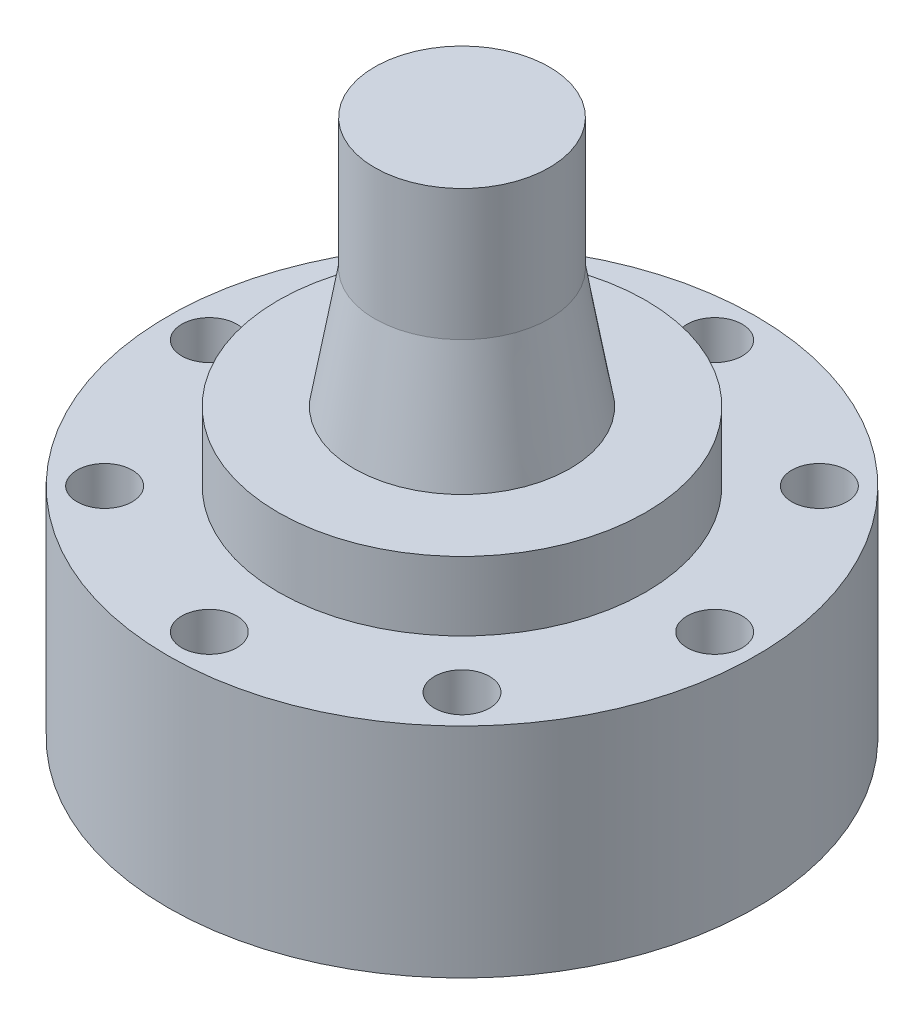
from build123d import *

# Parameters (mm, degrees)
SKETCH_1_R           = 12.8
EXTRUDE_1_DEPTH      = 9.5
EXTRUDE_1_DEPTH_BACK = 3
SKETCH_24_R          = 1.2
CUT_EXTRUDE_1_DEPTH  = 24.4
SKETCH_25_R          = 5.1
CUT_EXTRUDE_2_DEPTH  = 6
SKETCH_26_R          = 12.8
SKETCH_26_R_2        = 8
CUT_EXTRUDE_4_DEPTH  = 3


with BuildPart() as part:
    # 스케치1 → 보스-돌출1 (new body, two sides)
    with BuildSketch(Plane(origin=(0, 0, 0), x_dir=(1, 0, 0), z_dir=(0, 1, 0))) as extrude_1_sk:
        Circle(SKETCH_1_R)
    extrude(amount=EXTRUDE_1_DEPTH)
    extrude(extrude_1_sk.sketch, amount=-EXTRUDE_1_DEPTH_BACK)

    # 스케치18 → 회전1 (revolve)
    with BuildSketch(Plane.XY):
        Polygon((0, 9.5), (-4.7, 9.5), (-3.8, 14.7), (-3.8, 20.4), (0, 20.4), (0, 14.7), align=None)
    revolve(axis=Axis((0, 15.188164867, 0), (0, -1, 0)))

    # 스케치24 → 컷-돌출1 (cut, through all)
    with BuildSketch(Plane.XZ.offset(3)):
        with Locations((0, 11)):
            Circle(SKETCH_24_R)
        with Locations((7.778174593, 7.778174593)):
            Circle(SKETCH_24_R)
        with Locations((11, 0)):
            Circle(SKETCH_24_R)
        with Locations((0, -11)):
            Circle(SKETCH_24_R)
        with Locations((-7.778174593, -7.778174593)):
            Circle(SKETCH_24_R)
        with Locations((-7.778174593, 7.778174593)):
            Circle(SKETCH_24_R)
        with Locations((7.778174593, -7.778174593)):
            Circle(SKETCH_24_R)
        with Locations((-11, 0)):
            Circle(SKETCH_24_R)
    extrude(amount=-CUT_EXTRUDE_1_DEPTH, mode=Mode.SUBTRACT)

    # 스케치25 → 컷-돌출2 (cut)
    with BuildSketch(Plane.XZ.offset(3)):
        Circle(SKETCH_25_R)
    extrude(amount=-CUT_EXTRUDE_2_DEPTH, mode=Mode.SUBTRACT)

    # 스케치26 → 컷-돌출4 (cut)
    with BuildSketch(Plane(origin=(0, 9.5, 0), x_dir=(1, 0, 0), z_dir=(0, 1, 0))):
        Circle(SKETCH_26_R)
        Circle(SKETCH_26_R_2, mode=Mode.SUBTRACT)
    extrude(amount=-CUT_EXTRUDE_4_DEPTH, mode=Mode.SUBTRACT)


solid = part.part
